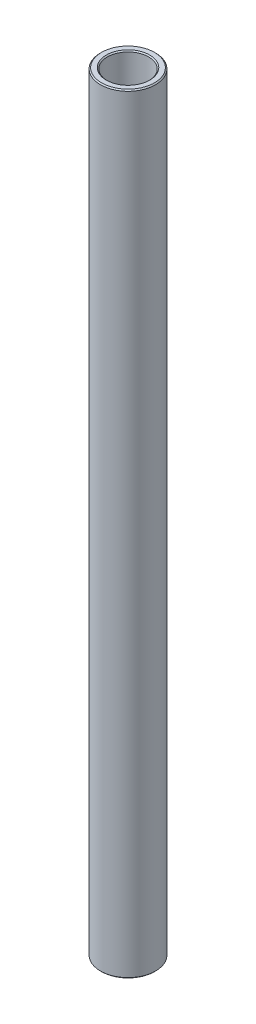
from build123d import *

# Parameters (mm, degrees)
SKETCH1_W     = 1.5875
SKETCH1_H     = 177.460231939
CHAMFER1_SIZE = 0.254


with BuildPart() as part:
    # Sketch1 → Revolve1 (revolve)
    with BuildSketch(Plane.XY):
        with Locations((5.55625, 220.4925059)):
            Rectangle(SKETCH1_W, SKETCH1_H)
    revolve(axis=Axis((0, 122.23738993, 0), (0, 1, 0)))

    # Chamfer1
    chamfer1_edges = [part.edges().sort_by_distance(p)[0] for p in [
        (-6.35, 131.76238993, 0),
        (-6.35, 309.222621869, 0),
        (-4.7625, 309.222621869, 0),
        (-4.7625, 131.76238993, 0),
    ]]
    chamfer(chamfer1_edges, length=CHAMFER1_SIZE)


solid = part.part
